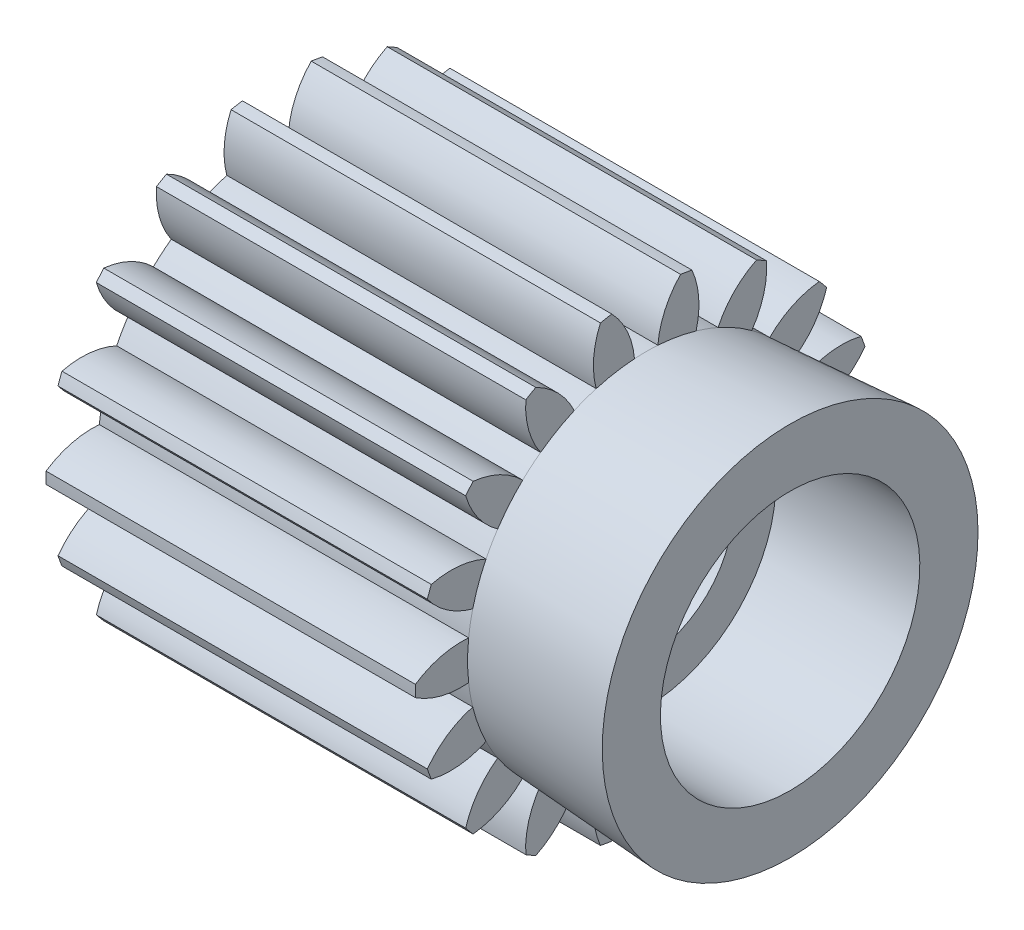
from build123d import *

# Parameters (mm, degrees)
BASPROSKE_W     = 12.7
BASPROSKE_H     = 7.9375
TOOTHCUT_DEPTH  = 17.949861725
TEETHCUTS_COUNT = 18
TEETHCUTS_ANGLE = 340
BORSKE_R        = 3
BORE_DEPTH      = 50.8000508


with BuildPart() as part:
    # BasProSke → Base-Revolve (revolve)
    with BuildSketch(Plane(origin=(0, 0, 0), x_dir=(1, 0, 0), z_dir=(0, 1, 0)), mode=Mode.PRIVATE) as base_revolve_sk:
        with Locations((6.35, 3.96875)):
            Rectangle(BASPROSKE_W, BASPROSKE_H)
    revolve(base_revolve_sk.sketch.rotate(Axis((-10, 0, 0), (1, 0, 0)), 180), axis=Axis((-10, 0, 0), (1, 0, 0)))

    # TooCutSke → ToothCut (cut, through all)
    with BuildSketch(Plane(origin=(0, 0, 0), x_dir=(0, 0, -1), z_dir=(1, 0, 0))):
        with BuildLine():
            ThreePointArc((0.401805019, 6.127289689), (0, 6.14045), (-0.401805019, 6.127289689))
            ThreePointArc((-0.401805019, 6.127289689), (-0.651999955, 7.068698885), (-1.203877601, 7.87136933))
            ThreePointArc((-1.203877601, 7.87136933), (0, 7.9629), (1.203877601, 7.87136933))
            ThreePointArc((1.203877601, 7.87136933), (0.651999955, 7.068698885), (0.401805019, 6.127289689))
        make_face()
    toothcut = extrude(amount=TOOTHCUT_DEPTH, mode=Mode.SUBTRACT)

    # TeethCuts: ToothCut ×18 about axis
    teethcuts_axis = Axis((-10, 0, 0), (1, 0, 0))
    for i in range(1, TEETHCUTS_COUNT):
        add(toothcut.rotate(teethcuts_axis, i * TEETHCUTS_ANGLE / (TEETHCUTS_COUNT - 1)), mode=Mode.SUBTRACT)

    # BorSke → Bore (cut, symmetric)
    with BuildSketch(Plane(origin=(0, 0, 0), x_dir=(0, 0, -1), z_dir=(1, 0, 0))):
        with Locations(Location((0, 0, 0), (0, 0, 180))):
            Circle(BORSKE_R)
    extrude(amount=BORE_DEPTH, both=True, mode=Mode.SUBTRACT)

    # Sketch1 → Revolve1 (revolve)
    with BuildSketch(Plane.XY, mode=Mode.PRIVATE) as revolve1_sk:
        Polygon((12.7, 6.14045), (17.65, 6.46), (17.65, 4.46), (12.7, 4.46), align=None)
    revolve(revolve1_sk.sketch.rotate(Axis((12.7, 0, 0), (1, 0, 0)), 180), axis=Axis((12.7, 0, 0), (1, 0, 0)))


solid = part.part
